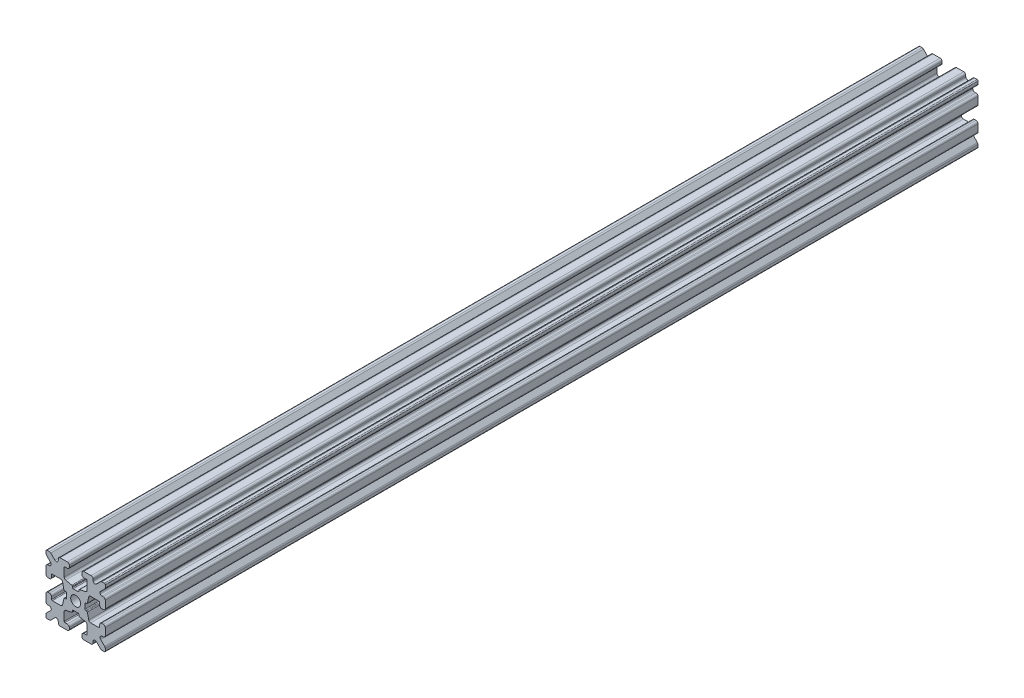
from build123d import *

# Parameters (mm, degrees)
SKETCH1_W           = 15
SKETCH1_H           = 15
SKETCH1_R           = 1.25
BOSS_EXTRUDE1_DEPTH = 110.42
FILLET1_R           = 0.25
CUT_EXTRUDE1_DEPTH  = 221.84
CUT_EXTRUDE3_DEPTH  = 221.84
FILLET3_R           = 0.5
FILLET4_R           = 0.5
FILLET5_R           = 3
FILLET6_R           = 0.2
CUT_EXTRUDE4_DEPTH  = 221.84
FILLET8_R           = 0.5
SKETCH6_W           = 5.1529354
SKETCH6_H           = 1.651
SKETCH6_W_2         = 1.651
SKETCH6_H_2         = 5.1529354
CUT_EXTRUDE5_DEPTH  = 221.84
FILLET10_R          = 0.2


with BuildPart() as part:
    # Sketch1 → Boss-Extrude1 (new body, symmetric)
    with BuildSketch(Plane.XY):
        Rectangle(SKETCH1_W, SKETCH1_H)
        Circle(SKETCH1_R, mode=Mode.SUBTRACT)
    extrude(amount=BOSS_EXTRUDE1_DEPTH, both=True)

    # Fillet1
    fillet1_edges = [part.edges().sort_by_distance(p)[0] for p in [
        (7.5, -7.5, 0),
        (-7.5, -7.5, 0),
        (-7.5, 7.5, 0),
        (7.5, 7.5, 0),
    ]]
    fillet(fillet1_edges, radius=FILLET1_R)

    # Sketch2 → Cut-Extrude1 (cut, through all)
    with BuildSketch(Plane.XY.offset(110.42)):
        Polygon((-7.5, 1.6), (-6.1, 1.6), (-6.1, 2.9), (-3.4, 2.9), (-3.4, -2.9), (-6.1, -2.9), (-6.1, -1.6), (-7.5, -1.6), align=None)
        Polygon((2.9, 6.1), (1.6, 6.1), (1.6, 7.5), (-1.6, 7.5), (-1.6, 6.1), (-2.9, 6.1), (-2.9, 3.4), (2.9, 3.4), align=None)
        Polygon((-1.6, -7.5), (-1.6, -6.1), (-2.9, -6.1), (-2.9, -3.4), (2.9, -3.4), (2.9, -6.1), (1.6, -6.1), (1.6, -7.5), align=None)
        Polygon((6.1, -2.9), (6.1, -1.6), (7.5, -1.6), (7.5, 1.6), (6.1, 1.6), (6.1, 2.9), (3.4, 2.9), (3.4, -2.9), align=None)
    extrude(amount=-CUT_EXTRUDE1_DEPTH, mode=Mode.SUBTRACT)

    # Sketch4 → Cut-Extrude3 (cut, through all)
    with BuildSketch(Plane.XY.offset(110.42)):
        Polygon((-3.4, 2.9), (-2.75, 0), (-3.4, -2.9), align=None)
        Polygon((-2.9, 3.4), (0, 2.75), (2.9, 3.4), align=None)
        Polygon((3.4, 2.9), (2.75, 0), (3.4, -2.9), align=None)
        Polygon((-2.9, -3.4), (0, -2.75), (2.9, -3.4), align=None)
    extrude(amount=-CUT_EXTRUDE3_DEPTH, mode=Mode.SUBTRACT)

    # Fillet3
    fillet3_edges = [part.edges().sort_by_distance(p)[0] for p in [
        (1.6, -7.5, 0),
        (-1.6, -7.5, 0),
        (-1.6, -6.1, 0),
        (1.6, -6.1, 0),
        (6.1, 1.6, 0),
        (7.5, 1.6, 0),
        (7.5, -1.6, 0),
        (6.1, -1.6, 0),
        (-7.5, -1.6, 0),
        (-7.5, 1.6, 0),
        (-6.1, 1.6, 0),
        (-6.1, -1.6, 0),
        (-1.6, 6.1, 0),
        (-1.6, 7.5, 0),
        (1.6, 7.5, 0),
        (1.6, 6.1, 0),
    ]]
    fillet(fillet3_edges, radius=FILLET3_R)

    # Fillet4
    fillet4_edges = [part.edges().sort_by_distance(p)[0] for p in [
        (-2.9, -3.4, 0),
        (2.9, -3.4, 0),
        (3.4, -2.9, 0),
        (3.4, 2.9, 0),
        (-3.4, 2.9, 0),
        (-3.4, -2.9, 0),
        (2.9, 3.4, 0),
        (-2.9, 3.4, 0),
    ]]
    fillet(fillet4_edges, radius=FILLET4_R)

    # Fillet5
    fillet5_edges = [part.edges().sort_by_distance(p)[0] for p in [
        (-2.75, 0, 0),
        (0, 2.75, 0),
        (2.75, 0, 0),
        (0, -2.75, 0),
    ]]
    fillet(fillet5_edges, radius=FILLET5_R)

    # Fillet6
    fillet6_edges = [part.edges().sort_by_distance(p)[0] for p in [
        (-2.9, -6.1, 0),
        (2.9, -6.1, 0),
        (6.1, -2.9, 0),
        (6.1, 2.9, 0),
        (-6.1, 2.9, 0),
        (-6.1, -2.9, 0),
        (2.9, 6.1, 0),
        (-2.9, 6.1, 0),
    ]]
    fillet(fillet6_edges, radius=FILLET6_R)

    # Sketch5 → Cut-Extrude4 (cut, through all)
    with BuildSketch(Plane.XY.offset(110.42)):
        Polygon((-7.5, 6.439339828), (-5.460660172, 4.4), (-7.5, 4.4), align=None)
        Polygon((-6.439339828, 7.5), (-4.4, 5.460660172), (-4.4, 7.5), align=None)
        Polygon((4.4, 7.5), (6.439339828, 7.5), (4.4, 5.460660172), align=None)
        Polygon((7.5, 6.439339828), (7.5, 4.4), (5.460660172, 4.4), align=None)
        Polygon((7.5, -6.439339828), (5.460660172, -4.4), (7.5, -4.4), align=None)
        Polygon((6.439339828, -7.5), (4.4, -5.460660172), (4.4, -7.5), align=None)
        Polygon((-4.4, -7.5), (-6.439339828, -7.5), (-4.4, -5.460660172), align=None)
        Polygon((-7.5, -6.439339828), (-7.5, -4.4), (-5.460660172, -4.4), align=None)
    extrude(amount=-CUT_EXTRUDE4_DEPTH, mode=Mode.SUBTRACT)

    # Fillet8
    fillet8_edges = [part.edges().sort_by_distance(p)[0] for p in [
        (-7.5, 4.4, 0),
        (-7.5, 6.439339828, 0),
        (-5.460660172, 4.4, 0),
        (7.5, -4.4, 0),
        (7.5, -6.439339828, 0),
        (5.460660172, -4.4, 0),
        (5.460660172, 4.4, 0),
        (7.5, 6.439339828, 0),
        (7.5, 4.4, 0),
        (-4.4, 7.5, 0),
        (-4.4, 5.460660172, 0),
        (-6.439339828, 7.5, 0),
        (-5.460660172, -4.4, 0),
        (-7.5, -6.439339828, 0),
        (-7.5, -4.4, 0),
        (4.4, 5.460660172, 0),
        (4.4, 7.5, 0),
        (6.439339828, 7.5, 0),
        (6.439339828, -7.5, 0),
        (4.4, -7.5, 0),
        (4.4, -5.460660172, 0),
        (-6.439339828, -7.5, 0),
        (-4.4, -5.460660172, 0),
        (-4.4, -7.5, 0),
    ]]
    fillet(fillet8_edges, radius=FILLET8_R)

    # Sketch6 → Cut-Extrude5 (cut, through all)
    with BuildSketch(Plane.XY.offset(110.42)):
        with Locations((4.9235323, 0)):
            Rectangle(SKETCH6_W, SKETCH6_H)
        with Locations((0, -4.9235323)):
            Rectangle(SKETCH6_W_2, SKETCH6_H_2)
        with Locations((-4.9235323, 0)):
            Rectangle(SKETCH6_W, SKETCH6_H)
        with Locations((0, 4.9235323)):
            Rectangle(SKETCH6_W_2, SKETCH6_H_2)
    extrude(amount=-CUT_EXTRUDE5_DEPTH, mode=Mode.SUBTRACT)

    # Fillet10
    fillet10_edges = [part.edges().sort_by_distance(p)[0] for p in [
        (0.8255, -2.935025862, 0),
        (-0.8255, -2.935025862, 0),
        (0.8255, -2.3470646, 0),
        (-0.8255, -2.3470646, 0),
        (2.935025862, 0.8255, 0),
        (2.935025862, -0.8255, 0),
        (2.3470646, 0.8255, 0),
        (2.3470646, -0.8255, 0),
        (-2.935025862, -0.8255, 0),
        (-2.935025862, 0.8255, 0),
        (-2.3470646, -0.8255, 0),
        (-2.3470646, 0.8255, 0),
        (-0.8255, 2.935025862, 0),
        (0.8255, 2.935025862, 0),
        (-0.8255, 2.3470646, 0),
        (0.8255, 2.3470646, 0),
    ]]
    fillet(fillet10_edges, radius=FILLET10_R)


solid = part.part
